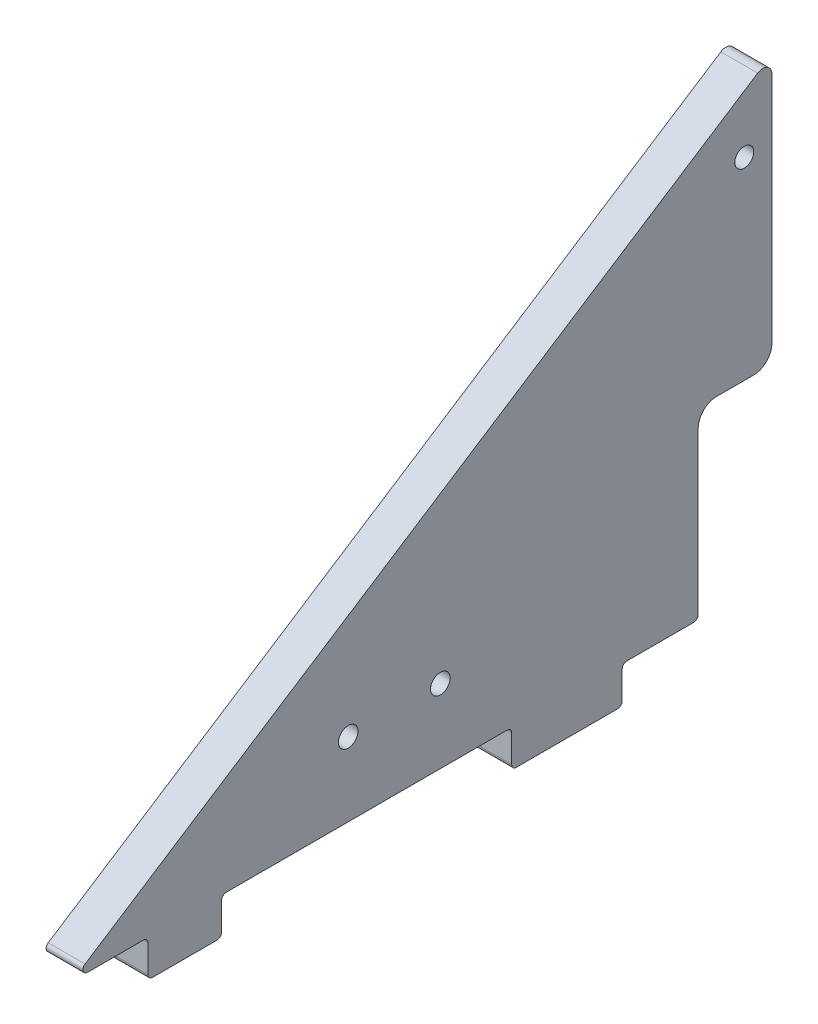
from build123d import *

# Parameters (mm, degrees)
SKETCH1_W                   = 38.1
SKETCH1_H                   = 12.7
SKETCH1_W_2                 = 25.4
BOSS_EXTRUDE1_DEPTH         = 6.35
F_1_4_CLEARANCE_HOLE1_D     = 6.7564
F_1_4_CLEARANCE_HOLE1_DEPTH = 12.7
BOSS_EXTRUDE2_DEPTH         = 12.7
TOP_FILLET_R                = 3.175
BOTTOM_FILLETS_R            = 1.5875
F_1_4_CLEARANCE_HOLE2_D     = 6.5278
F_1_4_CLEARANCE_HOLE2_DEPTH = 12.7
FILLET1_R                   = 6.35


with BuildPart() as part:
    # Sketch1 → Boss-Extrude1 (new body, symmetric)
    with BuildSketch(Plane(origin=(0, 0, 0), x_dir=(0, 0, -1), z_dir=(1, 0, 0))):
        Polygon((0, 139.7), (0, 0), (-215.9, 0), align=None)
        with Locations((-45.24375, -6.35)):
            Rectangle(SKETCH1_W, SKETCH1_H)
        with Locations((-177.00625, -6.35)):
            Rectangle(SKETCH1_W_2, SKETCH1_H)
    extrude(amount=BOSS_EXTRUDE1_DEPTH, both=True)

    # 1/4 Clearance Hole1
    with Locations(Plane(origin=(6.35, 0, 0), x_dir=(0, 0, -1), z_dir=(1, 0, 0))):
        with Locations((-88.9, 25.4), (-120.65, 25.4)):
            Hole(F_1_4_CLEARANCE_HOLE1_D / 2, depth=F_1_4_CLEARANCE_HOLE1_DEPTH)

    # Sketch13 → Boss-Extrude2 (add, through all)
    with BuildSketch(Plane.ZY.offset(6.35)):
        Polygon((-25.4, 156.135294118), (0, 139.7), (0, 63.5), (-25.4, 63.5), align=None)
    extrude(amount=-BOSS_EXTRUDE2_DEPTH)

    # top fillet
    top_fillet_edges = [part.edges().sort_by_distance(p)[0] for p in [
        (0, 156.135294118, -25.4),
    ]]
    fillet(top_fillet_edges, radius=TOP_FILLET_R)

    # bottom fillets
    bottom_fillets_edges = [part.edges().sort_by_distance(p)[0] for p in [
        (0, 0, 0),
        (0, 0, 26.19375),
        (0, -12.7, 26.19375),
        (0, -12.7, 64.29375),
        (0, 0, 64.29375),
        (0, 0, 164.30625),
        (0, -12.7, 164.30625),
        (0, -12.7, 189.70625),
        (0, 0, 189.70625),
        (0, 0, 215.9),
    ]]
    fillet(bottom_fillets_edges, radius=BOTTOM_FILLETS_R)

    # 1/4 Clearance Hole2
    with Locations(Plane(origin=(6.35, 0, 0), x_dir=(0, 0, -1), z_dir=(1, 0, 0))):
        with Locations((15.875, 130.175)):
            Hole(F_1_4_CLEARANCE_HOLE2_D / 2, depth=F_1_4_CLEARANCE_HOLE2_DEPTH)

    # Fillet1
    fillet1_edges = [part.edges().sort_by_distance(p)[0] for p in [
        (0, 63.5, -25.4),
        (0, 63.5, 0),
    ]]
    fillet(fillet1_edges, radius=FILLET1_R)


solid = part.part
